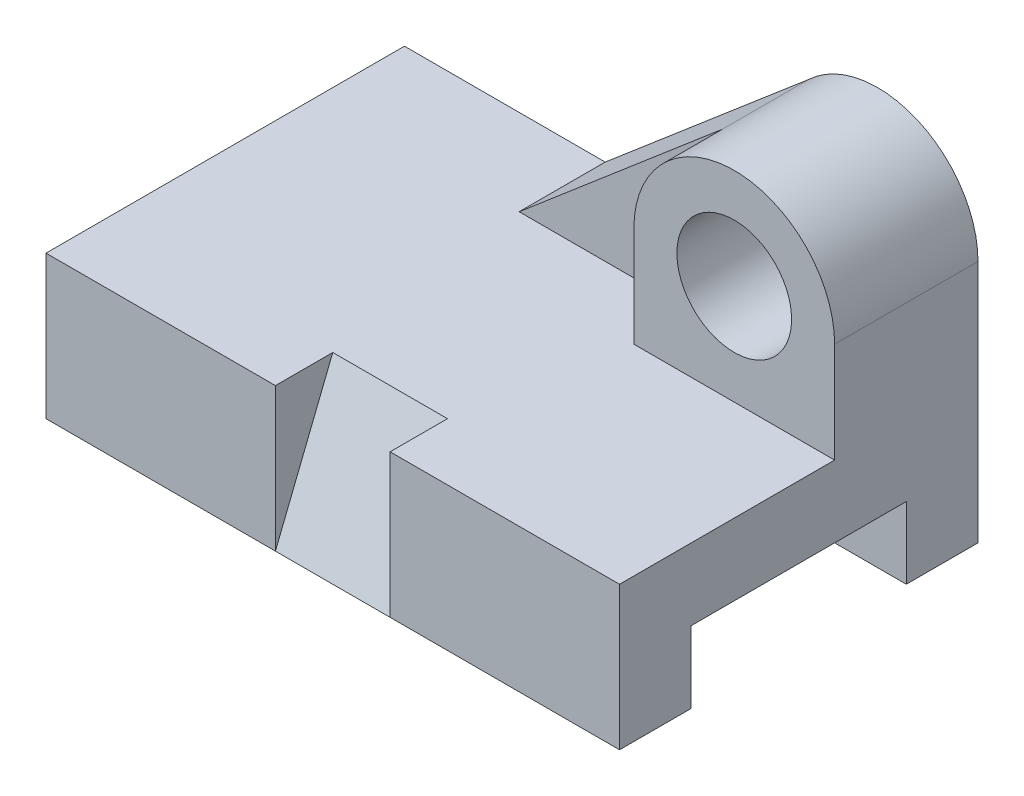
from build123d import *

# Parameters (mm, degrees)
SKETCH4_W           = 200
SKETCH4_H           = 125
BOSS_EXTRUDE2_DEPTH = 50
SKETCH6_W           = 75
SKETCH6_H           = 25
CUT_EXTRUDE1_DEPTH  = 201
SKETCH7_W           = 40
SKETCH7_H           = 50
CUT_EXTRUDE2_DEPTH  = 20
BOSS_EXTRUDE5_DEPTH = 40
SKETCH10_R          = 20
BOSS_EXTRUDE6_DEPTH = 50
BOSS_EXTRUDE8_DEPTH = 30


with BuildPart() as part:
    # Sketch4 → Boss-Extrude2 (new body)
    with BuildSketch(Plane(origin=(0, 0, 0), x_dir=(1, 0, 0), z_dir=(0, 1, 0))):
        with Locations((12.028985507, -7.427536232)):
            Rectangle(SKETCH4_W, SKETCH4_H)
    extrude(amount=BOSS_EXTRUDE2_DEPTH)

    # Sketch6 → Cut-Extrude1 (cut, through all)
    with BuildSketch(Plane.ZY.offset(87.971014493)):
        with Locations((7.427536232, 12.5)):
            Rectangle(SKETCH6_W, SKETCH6_H)
    extrude(amount=-CUT_EXTRUDE1_DEPTH, mode=Mode.SUBTRACT)

    # Sketch7 → Cut-Extrude2 (cut)
    with BuildSketch(Plane.XY.offset(69.927536232)):
        with Locations((12.028985507, 25)):
            Rectangle(SKETCH7_W, SKETCH7_H)
    extrude(amount=-CUT_EXTRUDE2_DEPTH, mode=Mode.SUBTRACT)

    # Sketch9 → Boss-Extrude5 (add)
    with BuildSketch(Plane.ZY.offset(-32.028985507)):
        Polygon((49.927536232, 50), (69.927536232, 0), (49.927536232, 0), align=None)
    extrude(amount=BOSS_EXTRUDE5_DEPTH)

    # Sketch10 → Boss-Extrude6 (add)
    with BuildSketch(Plane(origin=(0, 0, -55.072463768), x_dir=(-1, 0, 0), z_dir=(0, 0, -1))):
        with BuildLine():
            Line((-42.028985507, 50), (-112.028985507, 50))
            Line((-112.028985507, 50), (-112.028985507, 85))
            ThreePointArc((-112.028985507, 85), (-77.028985507, 120), (-42.028985507, 85))
            Line((-42.028985507, 85), (-42.028985507, 50))
        make_face()
        with Locations((-77.028985507, 85)):
            Circle(SKETCH10_R, mode=Mode.SUBTRACT)
    extrude(amount=-BOSS_EXTRUDE6_DEPTH)

    # Sketch11 → Boss-Extrude8 (add)
    with BuildSketch(Plane(origin=(0, 0, -55.072463768), x_dir=(-1, 0, 0), z_dir=(0, 0, -1))):
        with BuildLine():
            Line((-42.028985507, 50), (17.971014493, 50))
            Line((17.971014493, 50), (-52.905907859, 110.358965373))
            ThreePointArc((-52.905907859, 110.358965373), (-44.862949711, 98.796598898), (-42.028985507, 85))
            Line((-42.028985507, 85), (-42.028985507, 50))
        make_face()
    extrude(amount=-BOSS_EXTRUDE8_DEPTH)


solid = part.part
